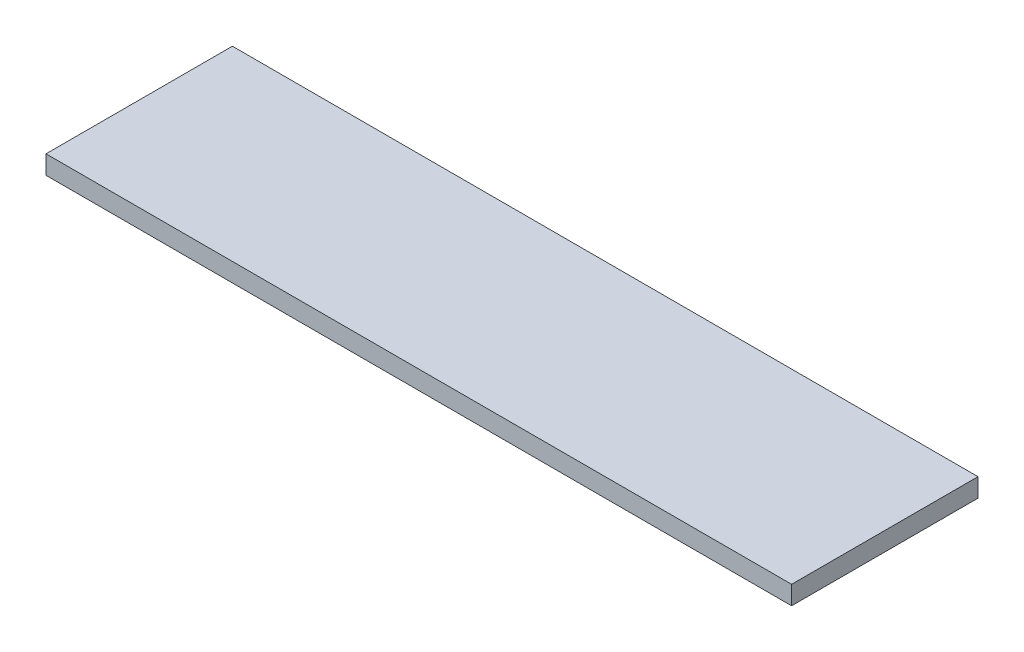
from build123d import *

# Parameters (mm, degrees)
SKETCH1_W           = 400
SKETCH1_H           = 100
BOSS_EXTRUDE1_DEPTH = 10


with BuildPart() as part:
    # Sketch1 → Boss-Extrude1 (new body)
    with BuildSketch(Plane(origin=(0, 0, 0), x_dir=(1, 0, 0), z_dir=(0, 1, 0))):
        Rectangle(SKETCH1_W, SKETCH1_H)
    extrude(amount=BOSS_EXTRUDE1_DEPTH)


solid = part.part
